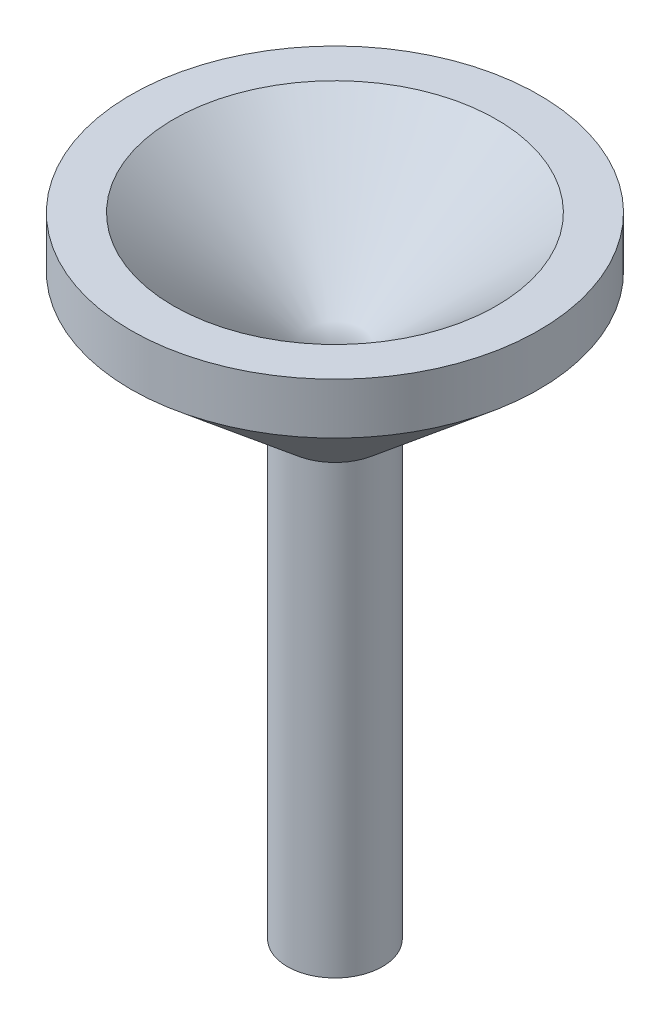
from build123d import *


with BuildPart() as part:
    # Sketch1 → Revolve1 (revolve)
    with BuildSketch(Plane.XY):
        Polygon((0, 0), (95, 80), (120, 80), (120, 50), (28, -27.473684211), (28, -290), (0, -290), align=None)
    revolve(axis=Axis((0, 178.391999298, 0), (0, -1, 0)))


solid = part.part
